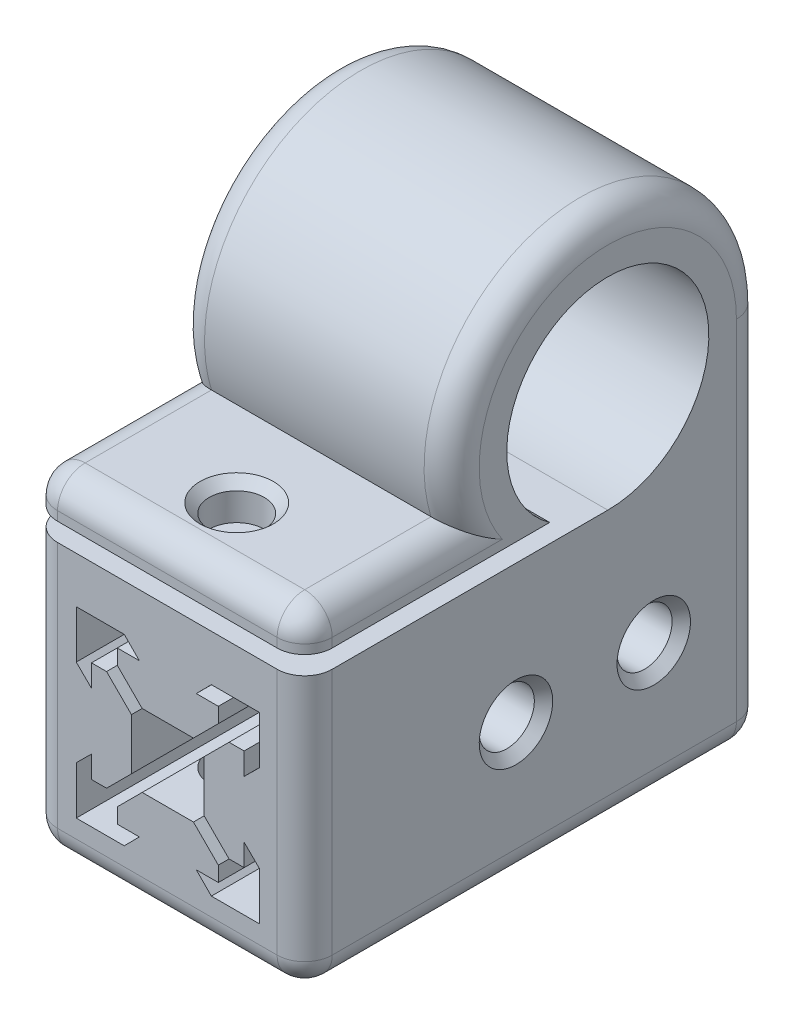
from build123d import *

# Parameters (mm, degrees)
BOSS_EXTRUDE1_DEPTH = 50
BOSS_EXTRUDE3_DEPTH = 29.899298
SKETCH3_R           = 3
CUT_EXTRUDE1_DEPTH  = 30.899298
SKETCH4_R           = 3
CUT_EXTRUDE2_DEPTH  = 38.007847
FILLET1_R           = 3
CHAMFER1_SIZE       = 1


with BuildPart() as part:
    # Sketch1 → Boss-Extrude1 (new body)
    with BuildSketch(Plane.XY):
        Polygon((0, 15), (14.899298, 15), (14.899298, -14.949649), (-15, -14.949649), (-15, 15), align=None)
        Polygon((-9.966433, 9.966433), (-4.741433, 9.966433), (-3.1, 8.307461), (-5.5, 8.307461), (-5.5, 6.667461), (-2.79, 3.957461), (2.79, 3.957461), (5.5, 6.667461), (5.5, 8.307461), (3.1, 8.307461), (4.741433, 9.966433), (9.966433, 9.966433), (9.966433, 4.741433), (8.307461, 3.1), (8.307461, 5.5), (6.667461, 5.5), (3.957461, 2.79), (3.957461, -2.79), (6.667461, -5.5), (8.307461, -5.5), (8.307461, -3.1), (9.966433, -4.741433), (9.966433, -9.966433), (4.741433, -9.966433), (3.1, -8.307461), (5.5, -8.307461), (5.5, -6.667461), (2.79, -3.957461), (-2.79, -3.957461), (-5.5, -6.667461), (-5.5, -8.307461), (-3.1, -8.307461), (-4.741433, -9.966433), (-9.966433, -9.966433), (-9.966433, -4.741433), (-8.307461, -3.1), (-8.307461, -5.5), (-6.667461, -5.5), (-3.957461, -2.79), (-3.957461, 2.79), (-6.667461, 5.5), (-8.307461, 5.5), (-8.307461, 3.1), (-9.966433, 4.741433), align=None, mode=Mode.SUBTRACT)
    extrude(amount=BOSS_EXTRUDE1_DEPTH)

    # Sketch5 → Boss-Extrude3 (add, through all)
    with BuildSketch(Plane.ZY.offset(15)):
        with BuildLine():
            Line((0, 26), (0, 15))
            Line((0, 15), (17, 15))
            ThreePointArc((17, 15), (13.683375, 36.488088), (23.324555, 17))
            Line((23.324555, 17), (27.804488, 17))
            Line((27.804488, 17), (50, 17))
            Line((50, 17), (50, 21))
            Line((50, 21), (33.248077, 21))
            ThreePointArc((33.248077, 21), (19.528111, 42.810968), (0, 26))
        make_face()
    extrude(amount=-BOSS_EXTRUDE3_DEPTH)

    # Sketch3 → Cut-Extrude1 (cut, through all)
    with BuildSketch(Plane.ZY.offset(15)):
        with Locations((12, 0)):
            Circle(SKETCH3_R)
        with Locations((27, 0)):
            Circle(SKETCH3_R)
    extrude(amount=-CUT_EXTRUDE1_DEPTH, mode=Mode.SUBTRACT)

    # Sketch4 → Cut-Extrude2 (cut, through all)
    with BuildSketch(Plane(origin=(0, 22.058198, 0), x_dir=(1, 0, 0), z_dir=(0, 1, 0))):
        with Locations((0, -42.5)):
            Circle(SKETCH4_R)
    extrude(amount=-CUT_EXTRUDE2_DEPTH, mode=Mode.SUBTRACT)

    # Fillet1
    fillet1_edges = [part.edges().sort_by_distance(p)[0] for p in [
        (-0.050351, -14.949649, 50),
        (14.899298, 0.025175, 50),
        (14.899298, 42.810968, 19.528111),
        (14.899298, 21, 41.624038),
        (14.899298, 19, 50),
        (-0.050351, 21, 50),
        (-15, 19, 50),
        (-15, 21, 41.624038),
        (-15, 42.810968, 19.528111),
        (14.899298, 0.025175, 0),
        (-0.050351, -14.949649, 0),
        (-15, 5.525175, 0),
        (-15, 0.025175, 50),
        (14.899298, -14.949649, 25),
        (-15, -14.949649, 25),
    ]]
    fillet(fillet1_edges, radius=FILLET1_R)

    # Chamfer1
    chamfer1_edges = [part.edges().sort_by_distance(p)[0] for p in [
        (14.899298, 0, 9),
        (-15, 0, 9),
        (14.899298, 0, 24),
        (-15, 0, 24),
        (-3, -14.949649, 42.5),
        (-3, 21, 42.5),
    ]]
    chamfer(chamfer1_edges, length=CHAMFER1_SIZE)


solid = part.part
